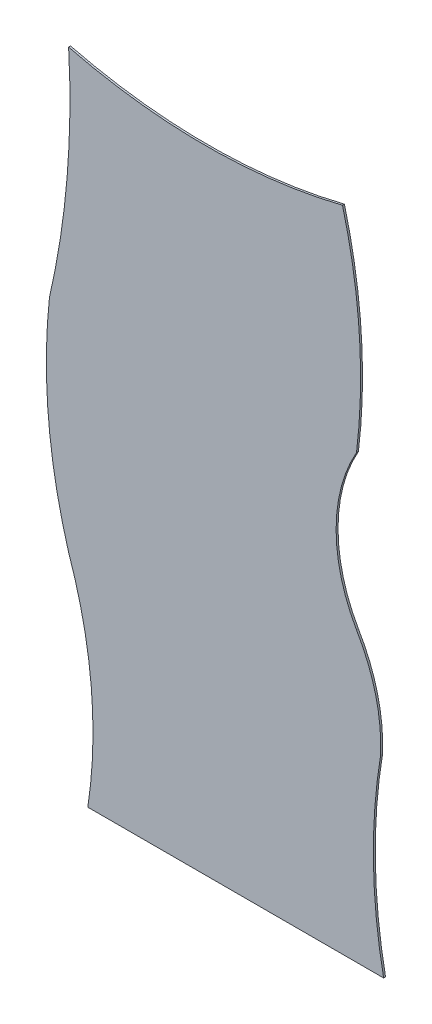
from build123d import *

# Parameters (mm, degrees)
SALIENTE_EXTRUIR1_DEPTH = 0.1


with BuildPart() as part:
    # Model → Saliente-Extruir1 (new body)
    with BuildSketch(Plane.XY):
        with BuildLine():
            Line((11.080118073, 12.100032616), (26.494172291, 12.100013434))
            ThreePointArc((26.494172291, 12.100013434), (25.962033929, 17.071786447), (26.334882576, 22.058035741))
            ThreePointArc((26.334882576, 22.058035741), (26.077271745, 24.671051179), (25.080126231, 27.100025003))
            ThreePointArc((25.080126231, 27.100025003), (24.017870658, 31.10002558), (25.080130581, 35.100025003))
            ThreePointArc((25.080130581, 35.100025003), (25.229028906, 40.534712367), (24.350613381, 45.900006732))
            ThreePointArc((24.350613381, 45.900006732), (17.215374003, 45.022517475), (10.080135103, 45.900010617))
            ThreePointArc((10.080135103, 45.900010617), (9.999432675, 39.964488004), (9.080130038, 34.100033704))
            ThreePointArc((9.080130038, 34.100033704), (9.035519695, 28.550523972), (10.080124055, 23.10003316))
            ThreePointArc((10.080124055, 23.10003316), (11.257202038, 17.661585333), (11.080118073, 12.100032616))
        make_face()
    extrude(amount=SALIENTE_EXTRUIR1_DEPTH)


solid = part.part
